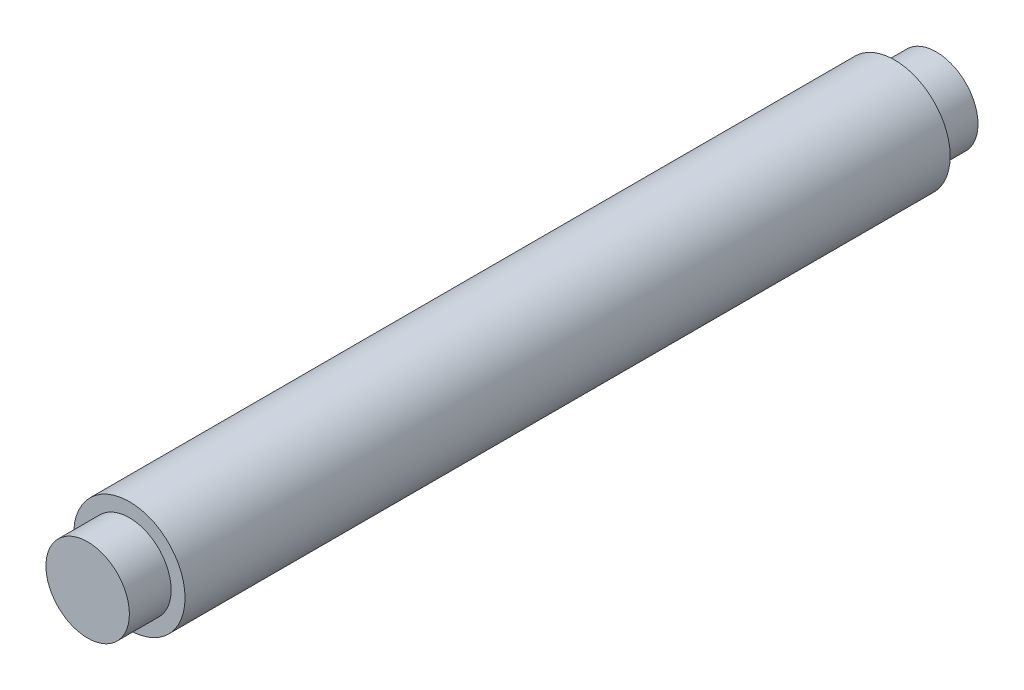
from build123d import *

# Parameters (mm, degrees)
SKETCH_1_R      = 4
EXTRUDE_1_DEPTH = 55
SKETCH_2_R      = 3
EXTRUDE_2_DEPTH = 3
SKETCH_3_R      = 3
EXTRUDE_3_DEPTH = 3


with BuildPart() as part:
    # 草图1 → 凸台-拉伸1 (new body)
    with BuildSketch(Plane.XY):
        Circle(SKETCH_1_R)
    extrude(amount=EXTRUDE_1_DEPTH)

    # 草图2 → 凸台-拉伸2 (add)
    with BuildSketch(Plane.XY.offset(55)):
        Circle(SKETCH_2_R)
    extrude(amount=EXTRUDE_2_DEPTH)

    # 草图3 → 凸台-拉伸3 (add)
    with BuildSketch(Plane(origin=(0, 0, 0), x_dir=(-1, 0, 0), z_dir=(0, 0, -1))):
        Circle(SKETCH_3_R)
    extrude(amount=EXTRUDE_3_DEPTH)


solid = part.part
